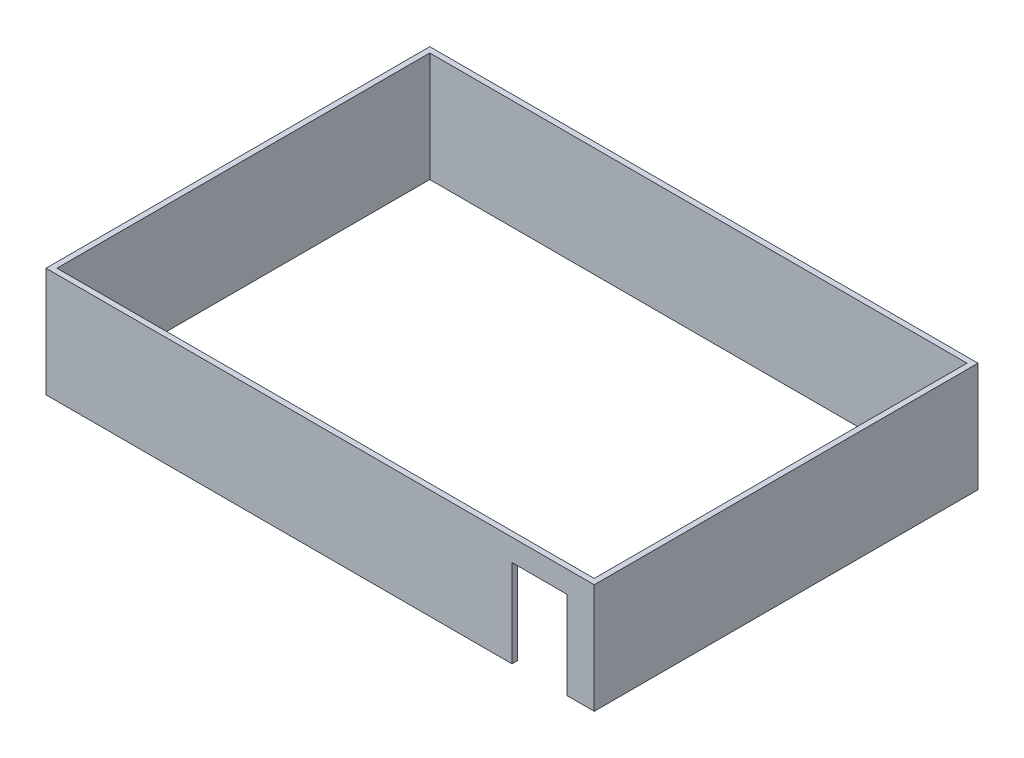
from build123d import *

# Parameters (mm, degrees)
SKETCH1_W           = 1000
SKETCH1_H           = 700
SKETCH1_W_2         = 980
SKETCH1_H_2         = 680
BOSS_EXTRUDE1_DEPTH = 200
SKETCH2_W           = 100
SKETCH2_H           = 160
CUT_EXTRUDE1_DEPTH  = 200


with BuildPart() as part:
    # Sketch1 → Boss-Extrude1 (new body)
    with BuildSketch(Plane(origin=(0, 0, 0), x_dir=(1, 0, 0), z_dir=(0, 1, 0))):
        Rectangle(SKETCH1_W, SKETCH1_H)
        Rectangle(SKETCH1_W_2, SKETCH1_H_2, mode=Mode.SUBTRACT)
    extrude(amount=BOSS_EXTRUDE1_DEPTH)

    # Sketch2 → Cut-Extrude1 (cut)
    with BuildSketch(Plane.XY.offset(350)):
        with Locations((400, 80)):
            Rectangle(SKETCH2_W, SKETCH2_H)
    extrude(amount=-CUT_EXTRUDE1_DEPTH, mode=Mode.SUBTRACT)


solid = part.part
